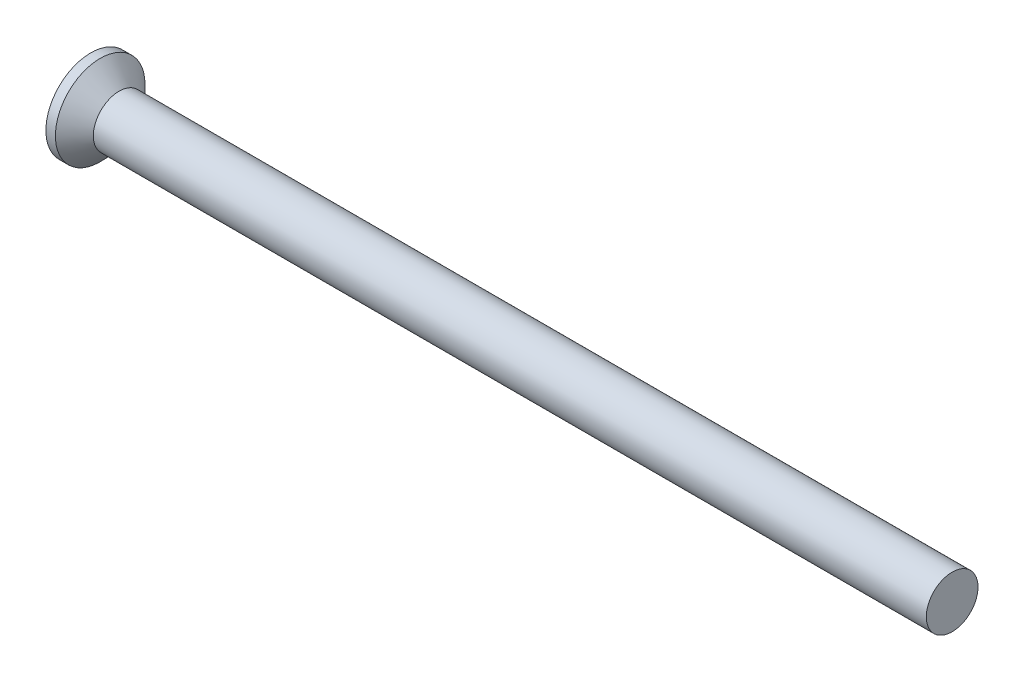
from build123d import *

# Parameters (mm, degrees)
CROSSRECESS_DEPTH = 0.825
DRAFT9_ANGLE      = 30
FILLET5_R         = 0.3
SKETCH10_W        = 0.5
SKETCH10_H        = 1.5


with BuildPart() as part:
    # Sketch1 → Base (revolve)
    with BuildSketch(Plane.XY):
        Polygon((50, 1.5), (2.65, 1.5), (1.65, 1.5), (0.55, 2.6), (0, 2.6), (0, 0), (50, 0), align=None)
    revolve(axis=Axis((4.515812911, 0, 0), (-1, 0, 0)))

    # Sketch6 → CrossRecess (cut)
    with BuildSketch(Plane(origin=(0, 0, 0), x_dir=(0, 0, -1), z_dir=(1, 0, 0))):
        Polygon((0.32, 0.32), (0.32, 1.6), (-0.32, 1.6), (-0.32, 0.32), (-1.6, 0.32), (-1.6, -0.32), (-0.32, -0.32), (-0.32, -1.6), (0.32, -1.6), (0.32, -0.32), (1.6, -0.32), (1.6, 0.32), align=None)
    extrude(amount=CROSSRECESS_DEPTH, mode=Mode.SUBTRACT)

    # Draft9
    draft9_faces = [part.faces().sort_by_distance(p)[0] for p in [
        (0.4125, -1.6, 0),
        (0.4125, 0, 1.6),
        (0.4125, 0, -1.6),
        (0.4125, 1.6, 0),
    ]]
    draft(draft9_faces, Plane(origin=(0, 2.6, 0), x_dir=(0, 0, -1), z_dir=(-1, 0, 0)), DRAFT9_ANGLE)

    # Fillet5
    fillet5_edges = [part.edges().sort_by_distance(p)[0] for p in [
        (0.4125, 0.32, 0.32),
        (0.4125, -0.32, 0.32),
        (0.4125, -0.32, -0.32),
        (0.4125, 0.32, -0.32),
    ]]
    fillet(fillet5_edges, radius=FILLET5_R)

    # Sketch10 → Revolve2 (revolve)
    with BuildSketch(Plane.XY):
        with Locations((1.9, 0.75)):
            Rectangle(SKETCH10_W, SKETCH10_H)
    revolve(axis=Axis((62.228915663, 0, 0), (-1, 0, 0)))


solid = part.part
